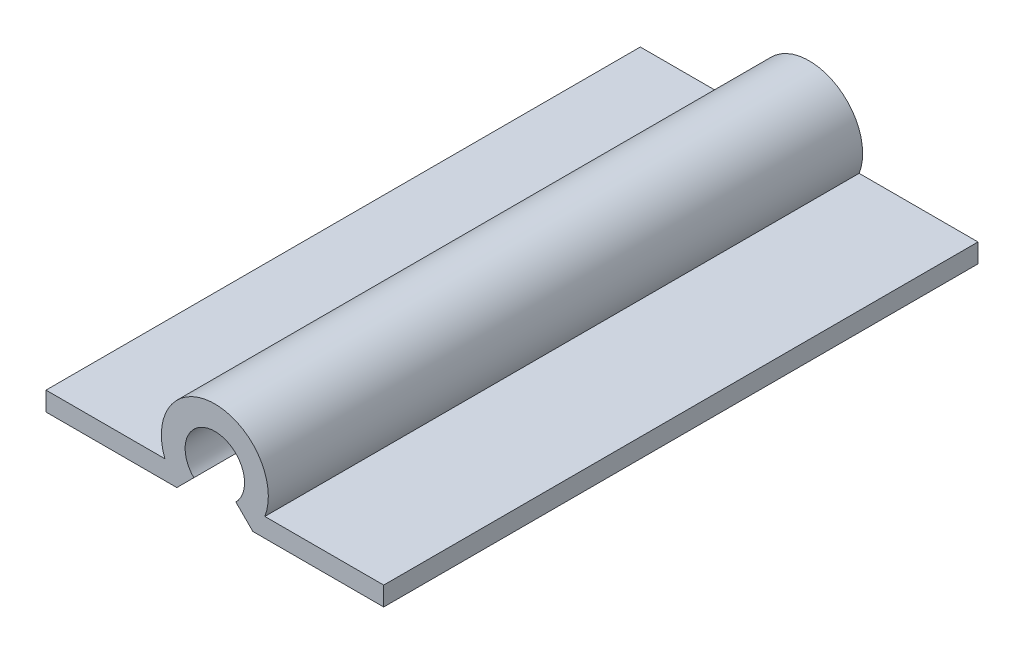
from build123d import *

# Parameters (mm, degrees)
BOSS_EXTRUDE1_DEPTH = 31.75


with BuildPart() as part:
    # Sketch1 → Boss-Extrude1 (new body)
    with BuildSketch(Plane.XY):
        with BuildLine():
            Line((-2.670777087, -1.016), (-9.020777087, -1.016))
            Line((-9.020777087, -1.016), (-9.020777087, -2.032))
            Line((-9.020777087, -2.032), (-2.032, -2.032))
            Line((-2.032, -2.032), (-1.122532015, -1.122532015))
            ThreePointArc((-1.122532015, -1.122532015), (0, 1.5875), (1.122532015, -1.122532015))
            Line((1.122532015, -1.122532015), (2.032, -2.032))
            Line((2.032, -2.032), (9.020777087, -2.032))
            Line((9.020777087, -2.032), (9.020777087, -1.016))
            Line((9.020777087, -1.016), (2.670777087, -1.016))
            ThreePointArc((2.670777087, -1.016), (0, 2.8575), (-2.670777087, -1.016))
        make_face()
    extrude(amount=BOSS_EXTRUDE1_DEPTH)


solid = part.part
